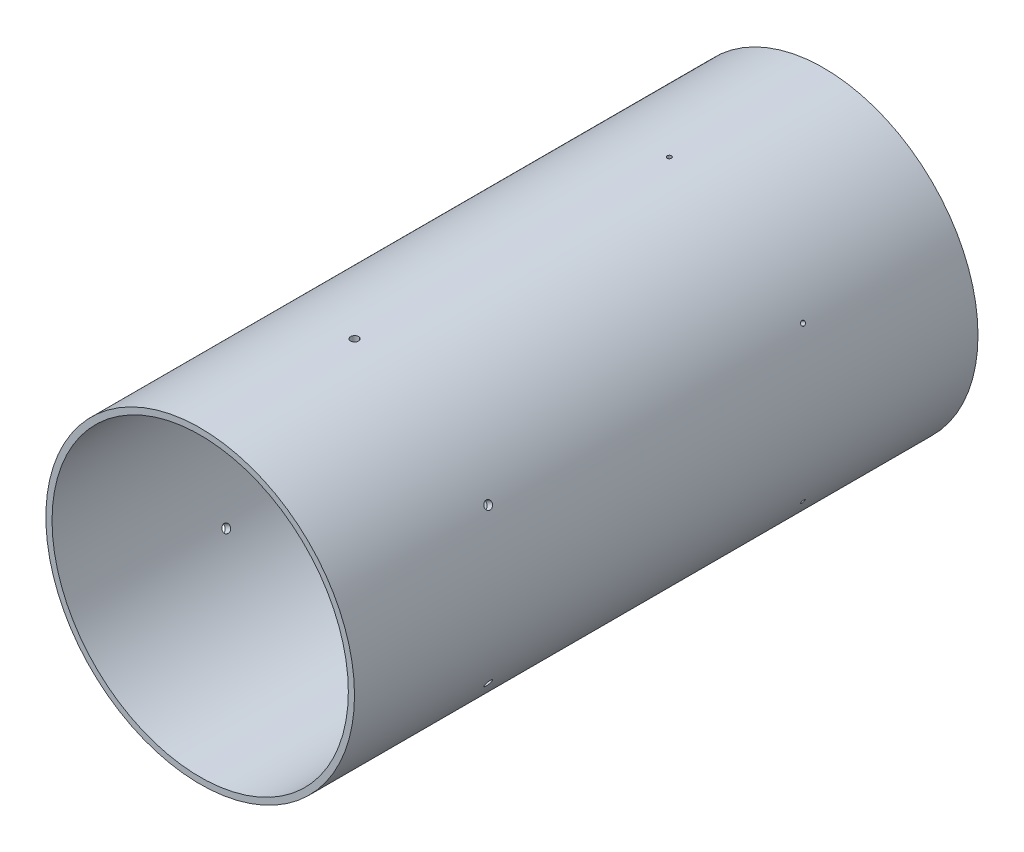
from build123d import *

# Parameters (mm, degrees)
SKETCH1_R                   = 79.375
SKETCH1_R_2                 = 76.2
BOSS_EXTRUDE1_DEPTH         = 320.675
F_4_40_TAPPED_HOLE1_REACH   = 368.517
F_4_40_TAPPED_HOLE1_BORE_R  = 1.1303
F_10_32_TAPPED_HOLE1_REACH  = 368.517
F_10_32_TAPPED_HOLE1_BORE_R = 2.0193
CIRPATTERN1_COUNT           = 6


with BuildPart() as part:
    # Sketch1 → Boss-Extrude1 (new body)
    with BuildSketch(Plane.XY):
        with Locations(Location((0, 0, 0), (0, 0, 180))):
            Circle(SKETCH1_R)
        with Locations(Location((0, 0, 0), (0, 0, 180))):
            Circle(SKETCH1_R_2, mode=Mode.SUBTRACT)
    extrude(amount=BOSS_EXTRUDE1_DEPTH)

    # #4-40 Tapped Hole1 bore → #4-40 Tapped Hole1 (cut, up to next)
    with BuildSketch(Plane(origin=(0, 79.375, 0), x_dir=(1, 0, 0), z_dir=(0, 1, 0)), mode=Mode.PRIVATE) as f_4_40_tapped_hole1_sk1:
        with Locations((0, -79.375)):
            Circle(F_4_40_TAPPED_HOLE1_BORE_R)
    f_4_40_tapped_hole1_tool1 = extrude(f_4_40_tapped_hole1_sk1.sketch, amount=-F_4_40_TAPPED_HOLE1_REACH, mode=Mode.PRIVATE) & part.part
    f_4_40_tapped_hole1 = f_4_40_tapped_hole1_tool1.solids().sort_by_distance((0, 79.375, 79.375))[0]
    add(f_4_40_tapped_hole1, mode=Mode.SUBTRACT)

    # #10-32 Tapped Hole1 bore → #10-32 Tapped Hole1 (cut, up to next)
    with BuildSketch(Plane(origin=(0, 79.375, 0), x_dir=(1, 0, 0), z_dir=(0, 1, 0)), mode=Mode.PRIVATE) as f_10_32_tapped_hole1_sk1:
        with Locations((0, -241.3)):
            Circle(F_10_32_TAPPED_HOLE1_BORE_R)
    f_10_32_tapped_hole1_tool1 = extrude(f_10_32_tapped_hole1_sk1.sketch, amount=-F_10_32_TAPPED_HOLE1_REACH, mode=Mode.PRIVATE) & part.part
    f_10_32_tapped_hole1 = f_10_32_tapped_hole1_tool1.solids().sort_by_distance((0, 79.375, 241.3))[0]
    add(f_10_32_tapped_hole1, mode=Mode.SUBTRACT)

    # CirPattern1: #4-40 Tapped Hole1, #10-32 Tapped Hole1 ×6 about axis
    cirpattern1_axis = Axis((0, 0, 320.675), (0, 0, 1))
    add([f_4_40_tapped_hole1.rotate(cirpattern1_axis, i * 360 / CIRPATTERN1_COUNT) for i in range(1, CIRPATTERN1_COUNT)], mode=Mode.SUBTRACT)
    add([f_10_32_tapped_hole1.rotate(cirpattern1_axis, i * 360 / CIRPATTERN1_COUNT) for i in range(1, CIRPATTERN1_COUNT)], mode=Mode.SUBTRACT)


solid = part.part
